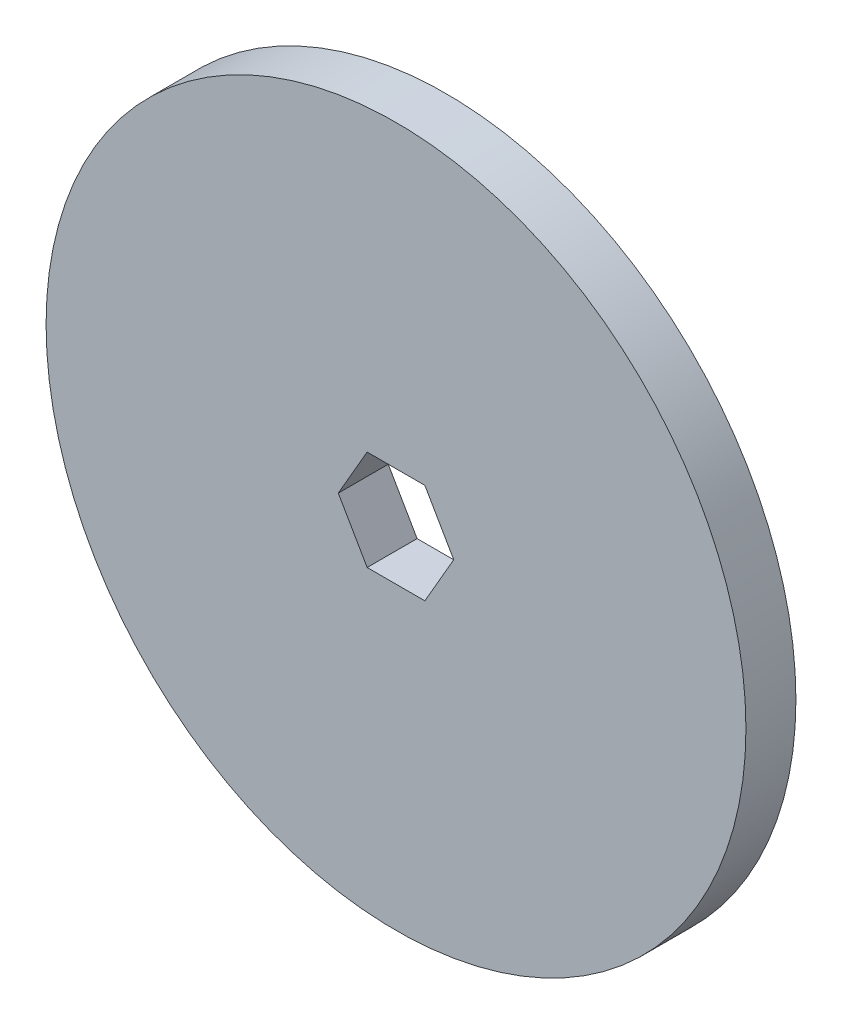
from build123d import *

# Parameters (mm, degrees)
SKETCH1_R           = 44.45
BOSS_EXTRUDE1_DEPTH = 3.175
CUT_EXTRUDE1_DEPTH  = 3.175


with BuildPart() as part:
    # Sketch1 → Boss-Extrude1 (new body, symmetric)
    with BuildSketch(Plane.XY):
        Circle(SKETCH1_R)
    extrude(amount=BOSS_EXTRUDE1_DEPTH, both=True)

    # Sketch2 → Cut-Extrude1 (cut, symmetric)
    with BuildSketch(Plane.XY):
        Polygon((7.332348419, 0), (3.666174209, 6.35), (-3.666174209, 6.35), (-7.332348419, 0), (-3.666174209, -6.35), (3.666174209, -6.35), align=None)
    extrude(amount=CUT_EXTRUDE1_DEPTH, both=True, mode=Mode.SUBTRACT)


solid = part.part
